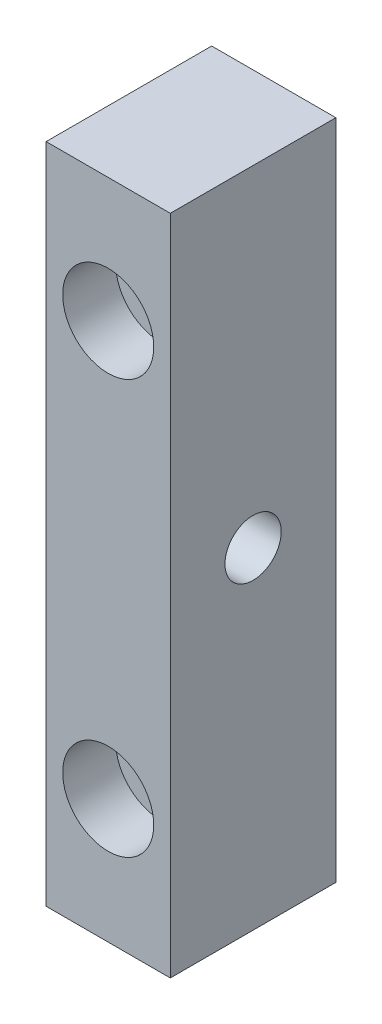
from build123d import *

# Parameters (mm, degrees)
SKETCH_1_W                   = 15
SKETCH_1_H                   = 80
EXTRUDE_1_DEPTH              = 20
HOLE_WIZARD_M8_1_D           = 6.8
HOLE_WIZARD_M8_1_DEPTH       = 19.75
HOLE_WIZARD_M8_1_TIP         = 2.042926105
HOLE_WIZARD_M6_1_D           = 6.4
HOLE_WIZARD_M6_1_CBORE_D     = 11
HOLE_WIZARD_M6_1_CBORE_DEPTH = 6.4


with BuildPart() as part:
    # 草图1 → 凸台-拉伸1 (new body)
    with BuildSketch(Plane.XY):
        Rectangle(SKETCH_1_W, SKETCH_1_H)
    extrude(amount=EXTRUDE_1_DEPTH)

    # M8 螺纹孔1
    with Locations(Plane(origin=(7.5, 0, 10), x_dir=(0, 0, 1), z_dir=(1, 0, 0))):
        with Locations((0, 0)):
            Hole(HOLE_WIZARD_M8_1_D / 2, depth=HOLE_WIZARD_M8_1_DEPTH)
            with Locations((0, 0, -(HOLE_WIZARD_M8_1_DEPTH + HOLE_WIZARD_M8_1_TIP / 2))):  # 118° drill point
                Cone(0, HOLE_WIZARD_M8_1_D / 2, HOLE_WIZARD_M8_1_TIP, mode=Mode.SUBTRACT)

    # M6 六角凹头螺钉的柱形沉头孔1 (through all)
    with Locations(Plane(origin=(0, 25, 20), x_dir=(1, 0, 0), z_dir=(0, 0, 1))):
        with Locations((0, 0), (0, -50)):
            CounterBoreHole(HOLE_WIZARD_M6_1_D / 2, HOLE_WIZARD_M6_1_CBORE_D / 2, HOLE_WIZARD_M6_1_CBORE_DEPTH)


solid = part.part
